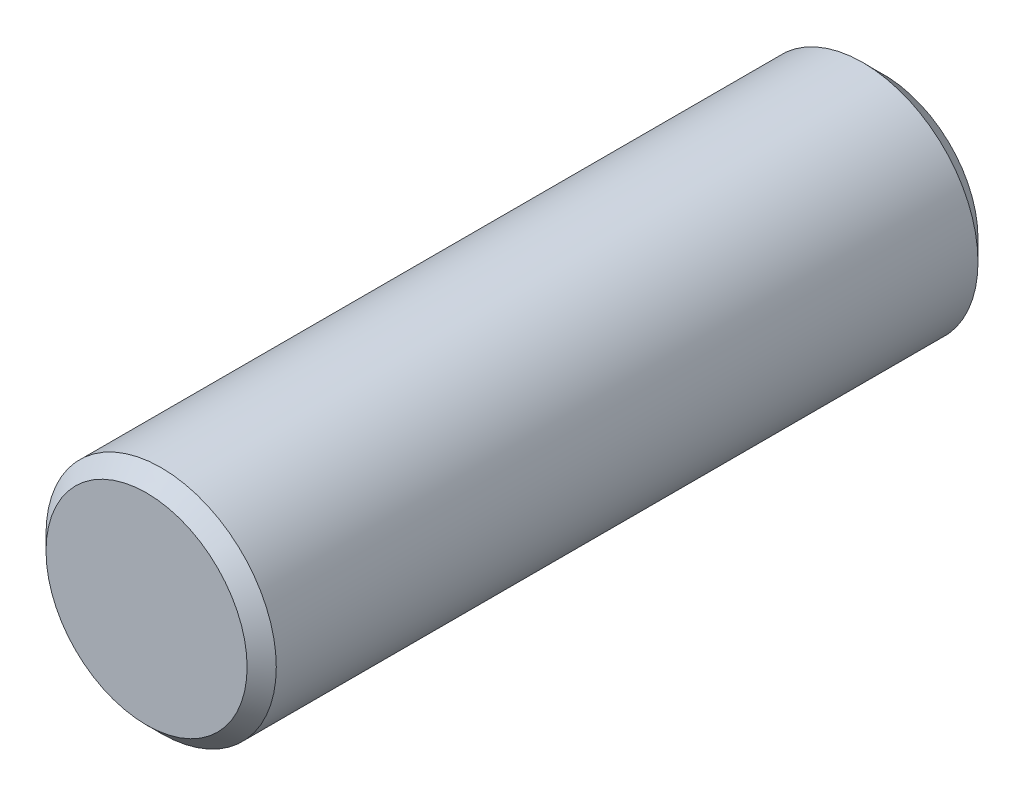
from build123d import *


with BuildPart() as part:
    # Sketch1 → Revolve1 (revolve)
    with BuildSketch(Plane(origin=(0, 0, 0), x_dir=(0, 0, -1), z_dir=(1, 0, 0))):
        Polygon((-6.35, 0), (-6.35, 1.732927829), (-6.098552829, 1.984375), (5.9944, 1.984375), (6.35, 1.628775), (6.35, 0), align=None)
    revolve(axis=Axis((0, 0, -6.35), (0, 0, 1)))


solid = part.part
